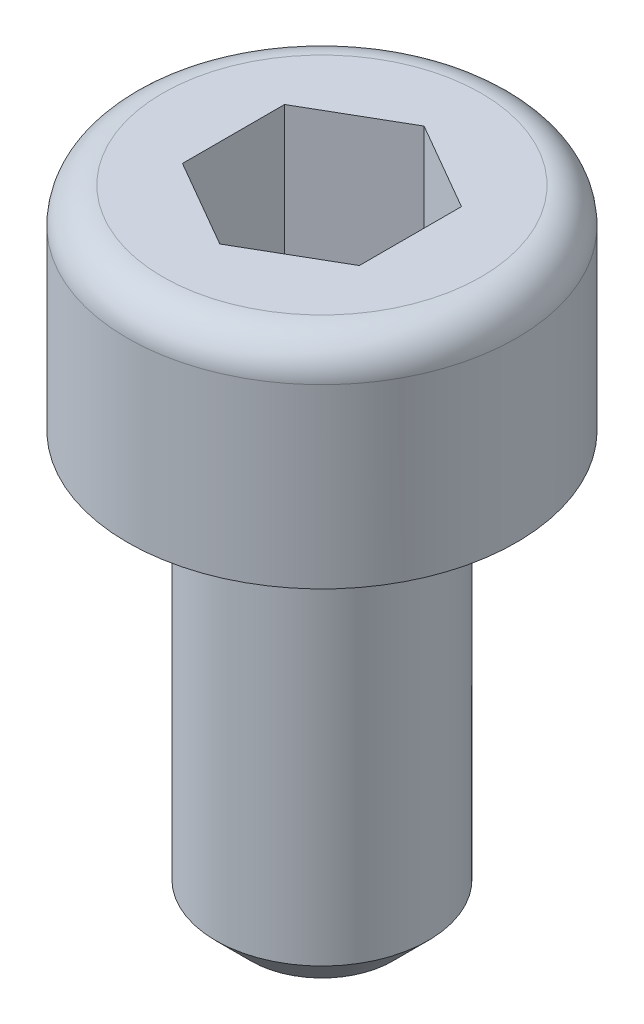
from build123d import *

# Parameters (mm, degrees)
CORTAR_EXTRUIR1_DEPTH = 2
CHAFL_N1_SIZE         = 0.5
REDONDEO1_R           = 0.5


with BuildPart() as part:
    # Croquis1 → Revolución1 (revolve)
    with BuildSketch(Plane.XY):
        Polygon((0, 0), (2.75, 0), (2.75, -3), (1.5, -3), (1.5, -9), (0, -9), align=None)
    revolve(axis=Axis((0, 0, 0), (0, -1, 0)))

    # Croquis2 → Cortar-Extruir1 (cut)
    with BuildSketch(Plane(origin=(0, 0, 0), x_dir=(1, 0, 0), z_dir=(0, 1, 0))):
        Polygon((1.25, 0.721687836), (0, 1.443375673), (-1.25, 0.721687836), (-1.25, -0.721687836), (0, -1.443375673), (1.25, -0.721687836), align=None)
    extrude(amount=-CORTAR_EXTRUIR1_DEPTH, mode=Mode.SUBTRACT)

    # Chaflán1
    chafl_n1_edges = [part.edges().sort_by_distance(p)[0] for p in [
        (-1.5, -9, 0),
    ]]
    chamfer(chafl_n1_edges, length=CHAFL_N1_SIZE)

    # Redondeo1
    redondeo1_edges = [part.edges().sort_by_distance(p)[0] for p in [
        (-2.75, 0, 0),
    ]]
    fillet(redondeo1_edges, radius=REDONDEO1_R)


solid = part.part
